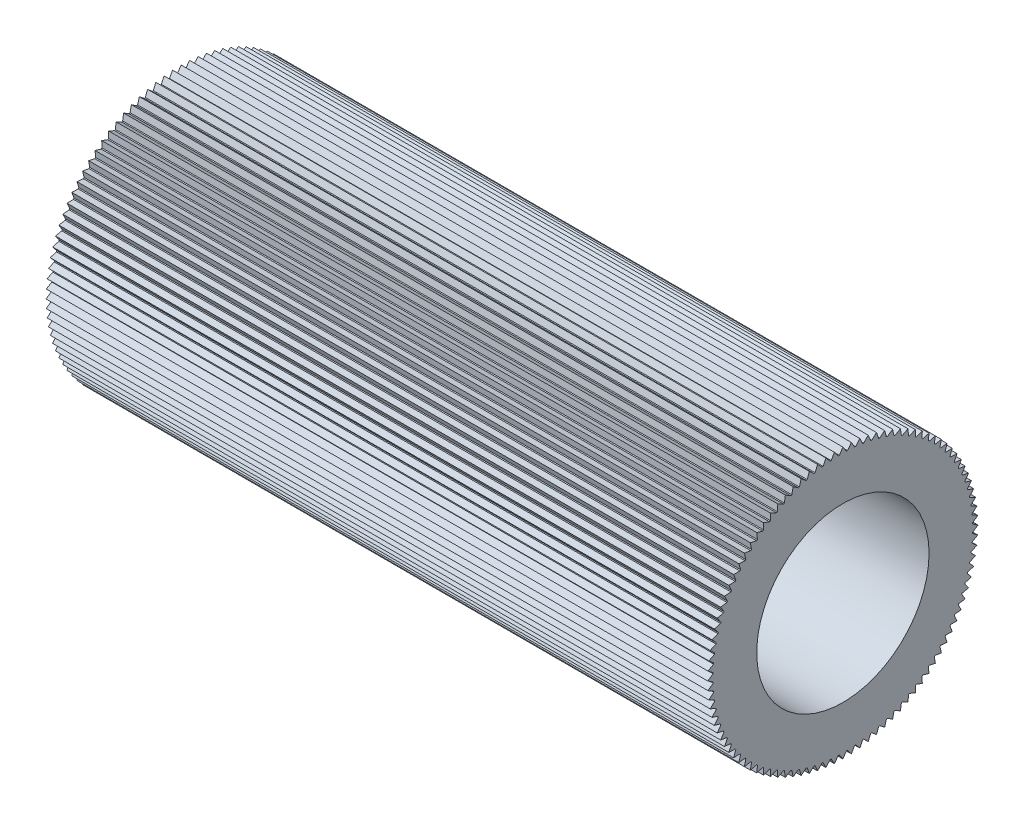
from build123d import *

# Parameters (mm, degrees)
SKETCH1_R           = 4.7625
SKETCH1_R_2         = 3.1623
BOSS_EXTRUDE1_DEPTH = 24.2824
BOSS_EXTRUDE2_DEPTH = 24.2824
CIRPATTERN3_COUNT   = 100


with BuildPart() as part:
    # Sketch1 → Boss-Extrude1 (new body)
    with BuildSketch(Plane(origin=(0, 0, 0), x_dir=(0, 0, -1), z_dir=(1, 0, 0))):
        Circle(SKETCH1_R)
        Circle(SKETCH1_R_2, mode=Mode.SUBTRACT)
    extrude(amount=BOSS_EXTRUDE1_DEPTH)

    # Sketch2 → Boss-Extrude2 (add)
    with BuildSketch(Plane.ZY):
        Polygon((-0.1524, 4.728848154), (0, 4.957661965), (0.1524, 4.728848154), align=None)
    boss_extrude2 = extrude(amount=-BOSS_EXTRUDE2_DEPTH)

    # CirPattern3: Boss-Extrude2 ×100 about axis
    cirpattern3_axis = Axis((0, 0, 0), (1, 0, 0))
    for i in range(1, CIRPATTERN3_COUNT):
        add(boss_extrude2.rotate(cirpattern3_axis, i * 360 / CIRPATTERN3_COUNT))


solid = part.part
